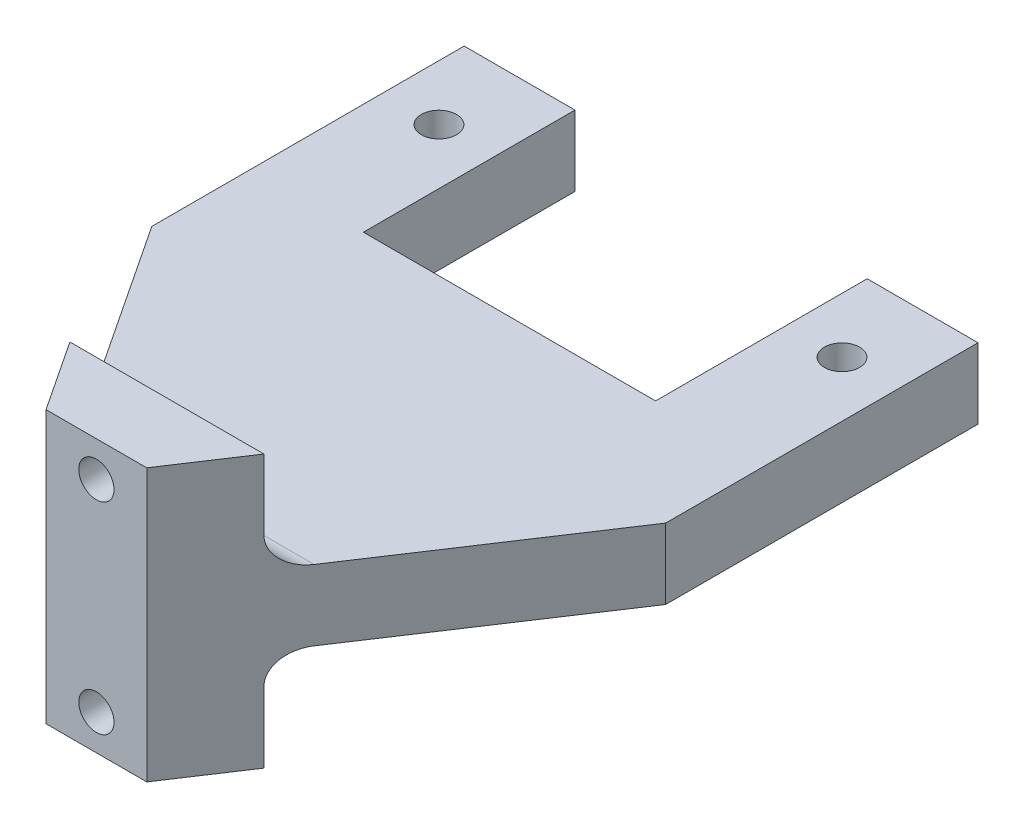
from build123d import *

# Parameters (mm, degrees)
SKETCH1_W           = 51
SKETCH1_H           = 62
BOSS_EXTRUDE1_DEPTH = 7
SKETCH2_W           = 29
SKETCH2_H           = 21
CUT_EXTRUDE1_DEPTH  = 8
SKETCH9_R           = 1.75
CUT_EXTRUDE4_DEPTH  = 8
CUT_EXTRUDE5_DEPTH  = 8
BOSS_EXTRUDE4_DEPTH = 10
SKETCH13_R          = 1.75
CUT_EXTRUDE6_DEPTH  = 63
FILLET1_R           = 3


with BuildPart() as part:
    # Sketch1 → Boss-Extrude1 (new body)
    with BuildSketch(Plane(origin=(0, 0, 0), x_dir=(1, 0, 0), z_dir=(0, 1, 0))):
        with Locations((25.5, 31)):
            Rectangle(SKETCH1_W, SKETCH1_H)
    extrude(amount=BOSS_EXTRUDE1_DEPTH)

    # Sketch2 → Cut-Extrude1 (cut, through all)
    with BuildSketch(Plane(origin=(0, 7, 0), x_dir=(1, 0, 0), z_dir=(0, 1, 0))):
        with Locations((25.5, 51.5)):
            Rectangle(SKETCH2_W, SKETCH2_H)
    extrude(amount=-CUT_EXTRUDE1_DEPTH, mode=Mode.SUBTRACT)

    # Sketch9 → Cut-Extrude4 (cut, through all)
    with BuildSketch(Plane(origin=(0, 7, 0), x_dir=(1, 0, 0), z_dir=(0, 1, 0))):
        with Locations((5.5, 54)):
            Circle(SKETCH9_R)
        with Locations((45.5, 54)):
            Circle(SKETCH9_R)
    extrude(amount=-CUT_EXTRUDE4_DEPTH, mode=Mode.SUBTRACT)

    # Sketch11 → Cut-Extrude5 (cut, through all)
    with BuildSketch(Plane(origin=(0, 7, 0), x_dir=(1, 0, 0), z_dir=(0, 1, 0))):
        Polygon((20.5, 0), (0, 31), (0, 0), align=None)
        Polygon((30.5, 0), (51, 31), (51, 0), align=None)
    extrude(amount=-CUT_EXTRUDE5_DEPTH, mode=Mode.SUBTRACT)

    # Sketch12 → Boss-Extrude4 (add)
    with BuildSketch(Plane(origin=(0, 7, 0), x_dir=(1, 0, 0), z_dir=(0, 1, 0))):
        Polygon((30.5, 0), (20.5, 0), (15.870967742, 7), (35.129032258, 7), align=None)
    boss_extrude4 = extrude(amount=BOSS_EXTRUDE4_DEPTH)

    # Mirror1: Boss-Extrude4 across plane
    add(boss_extrude4.mirror(Plane.ZX.offset(3.5)))

    # Sketch13 → Cut-Extrude6 (cut, through all)
    with BuildSketch(Plane.XY):
        with Locations((25.5, 13.5)):
            Circle(SKETCH13_R)
        with Locations((25.5, -6.5)):
            Circle(SKETCH13_R)
    extrude(amount=-CUT_EXTRUDE6_DEPTH, mode=Mode.SUBTRACT)

    # Fillet1
    fillet1_edges = [part.edges().sort_by_distance(p)[0] for p in [
        (25.5, 7, -7),
        (25.5, 0, -7),
    ]]
    fillet(fillet1_edges, radius=FILLET1_R)


solid = part.part
